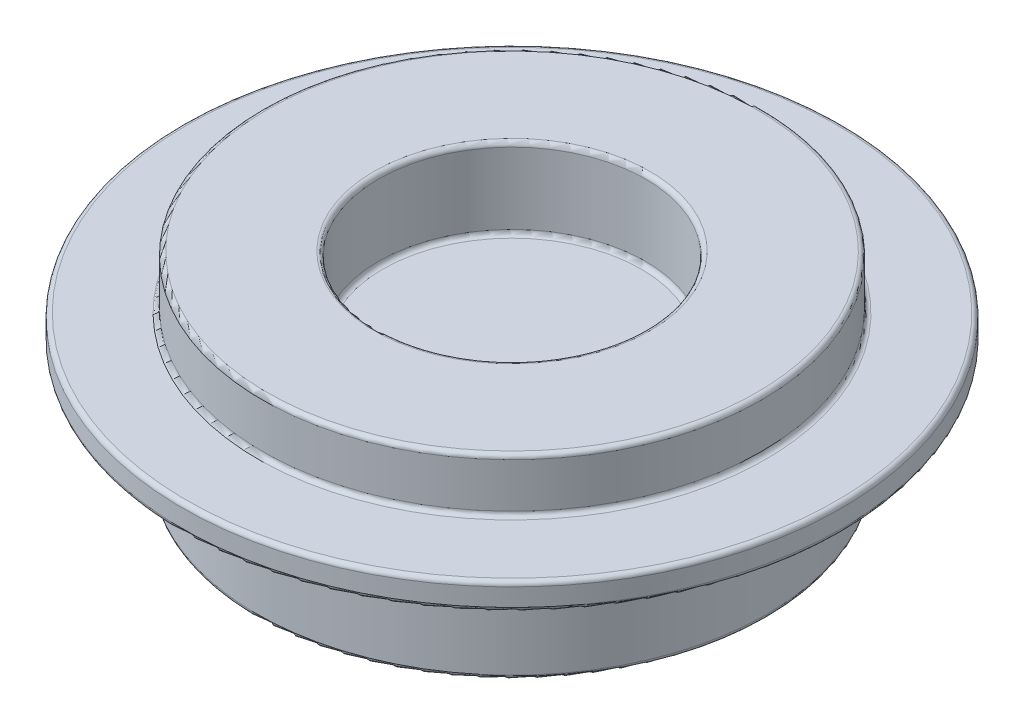
from build123d import *

# Parameters (mm, degrees)
FILLET1_R = 0.25


with BuildPart() as part:
    # Sketch1 → Revolve1 (revolve)
    with BuildSketch(Plane.XY):
        Polygon((0, 0), (0, 6.25), (-7.5, 6.25), (-7.5, 10.75), (-14, 10.75), (-14, 7.75), (-18.5, 7.75), (-18.5, 6.25), (-14.3125, 6.25), (-14.3125, 0), align=None)
    revolve(axis=Axis((0, 17.96875, 0), (0, -1, 0)))

    # Fillet1
    fillet1_edges = [part.edges().sort_by_distance(p)[0] for p in [
        (14, 10.75, 0),
        (7.5, 10.75, 0),
        (7.5, 6.25, 0),
        (14.3125, 0, 0),
        (14.3125, 6.25, 0),
        (18.5, 6.25, 0),
        (18.5, 7.75, 0),
        (14, 7.75, 0),
    ]]
    fillet(fillet1_edges, radius=FILLET1_R)


solid = part.part
